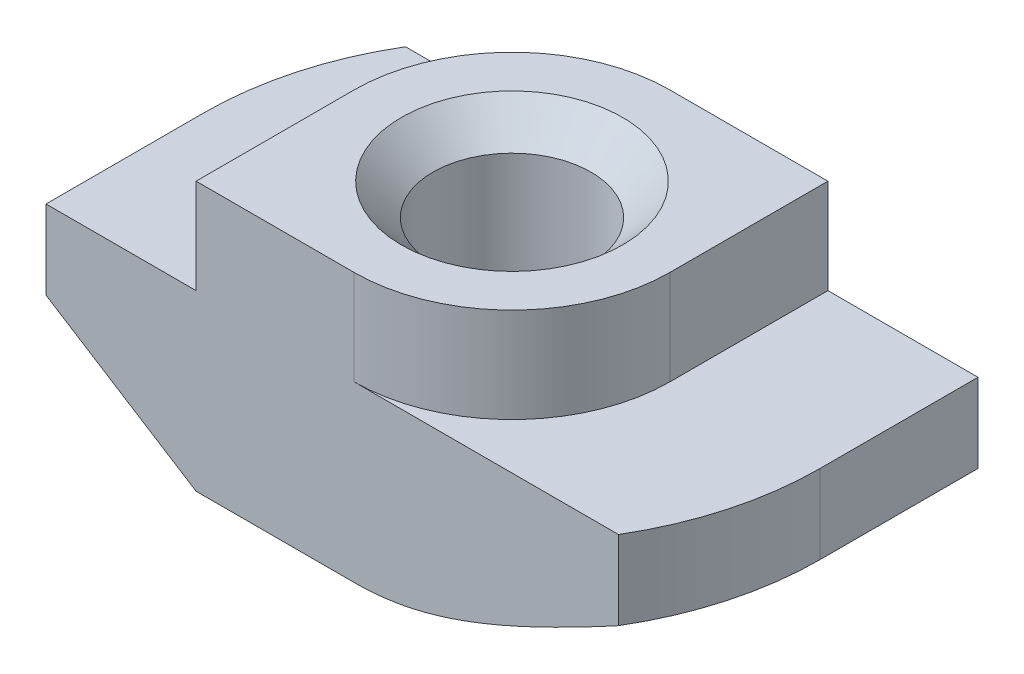
from build123d import *

# Parameters (mm, degrees)
EXTRUDE_1_DEPTH     = 5
CUT_EXTRUDE_1_DEPTH = 3
CUT_EXTRUDE_2_DEPTH = 6.5


with BuildPart() as part:
    # Эскиз1 → Бобышка-Вытянуть1 (new body, symmetric)
    with BuildSketch(Plane.XY):
        Polygon((5, 0), (-5, 0), (-5, -3), (-9.75, -3), (-9.75, -8.5), (9.75, -8.5), (9.75, -3), (5, -3), align=None)
    extrude(amount=EXTRUDE_1_DEPTH, both=True)

    # Эскиз3 → Отверстие обработанное метчиком M62 (revolve, cut)
    with BuildSketch(Plane(origin=(0, 0, 0), x_dir=(0, 0, 1), z_dir=(1, 0, 0))):
        Polygon((0, 0), (0, 8.5), (3.5, 8.5), (2.5, 7.5), (2.5, 1), (3.5, 0), align=None)
    revolve(axis=Axis((0, 6.35, 0), (0, -1, 0)), mode=Mode.SUBTRACT)

    # Эскиз4 → Вырез-Вытянуть1 (cut)
    with BuildSketch(Plane(origin=(0, 0, 0), x_dir=(1, 0, 0), z_dir=(0, 1, 0))):
        with BuildLine():
            Line((-5, 5), (-5, 0))
            ThreePointArc((-5, 0), (-3.535533906, 3.535533906), (0, 5))
            Line((0, 5), (-5, 5))
        make_face()
        with BuildLine():
            Line((0, -5), (5, -5))
            Line((5, -5), (5, 0))
            ThreePointArc((5, 0), (3.535533906, -3.535533906), (0, -5))
        make_face()
    extrude(amount=-CUT_EXTRUDE_1_DEPTH, mode=Mode.SUBTRACT)

    # Эскиз5 → Вырез-Вытянуть2 (cut, through all)
    with BuildSketch(Plane(origin=(0, -3, 0), x_dir=(1, 0, 0), z_dir=(0, 1, 0))):
        with BuildLine():
            Line((-9.75, 0), (-9.75, 5))
            Line((-9.75, 5), (-8.370334521, 5))
            ThreePointArc((-8.370334521, 5), (-9.398756875, 2.59342808), (-9.75, 0))
        make_face()
        with BuildLine():
            Line((9.75, 0), (9.75, -5))
            Line((9.75, -5), (8.370334521, -5))
            ThreePointArc((8.370334521, -5), (9.398756875, -2.59342808), (9.75, 0))
        make_face()
    extrude(amount=-CUT_EXTRUDE_2_DEPTH, mode=Mode.SUBTRACT)

    # Вырез-По траектории1: sweep along a path in Эскиз7
    with BuildLine(Plane.XZ.offset(8.5)) as sweep_1_path:
        Line((0, 9.75), (-9.75, 9.75))
        Line((-9.75, 9.75), (-9.75, 0))
        ThreePointArc((-9.75, 0), (-6.894291117, -6.894291117), (0, -9.75))
        Line((0, -9.75), (9.75, -9.75))
        Line((9.75, -9.75), (9.75, 0))
        ThreePointArc((9.75, 0), (6.894291117, 6.894291117), (0, 9.75))
    # Эскиз6 → Вырез-По траектории1 (sweep, cut)
    with BuildSketch(Plane.XY.offset(5)):
        Polygon((-9.75, -5.5), (-9.75, -8.5), (-5, -8.5), align=None)
    sweep(path=sweep_1_path.line, transition=Transition.RIGHT, mode=Mode.SUBTRACT)


solid = part.part
